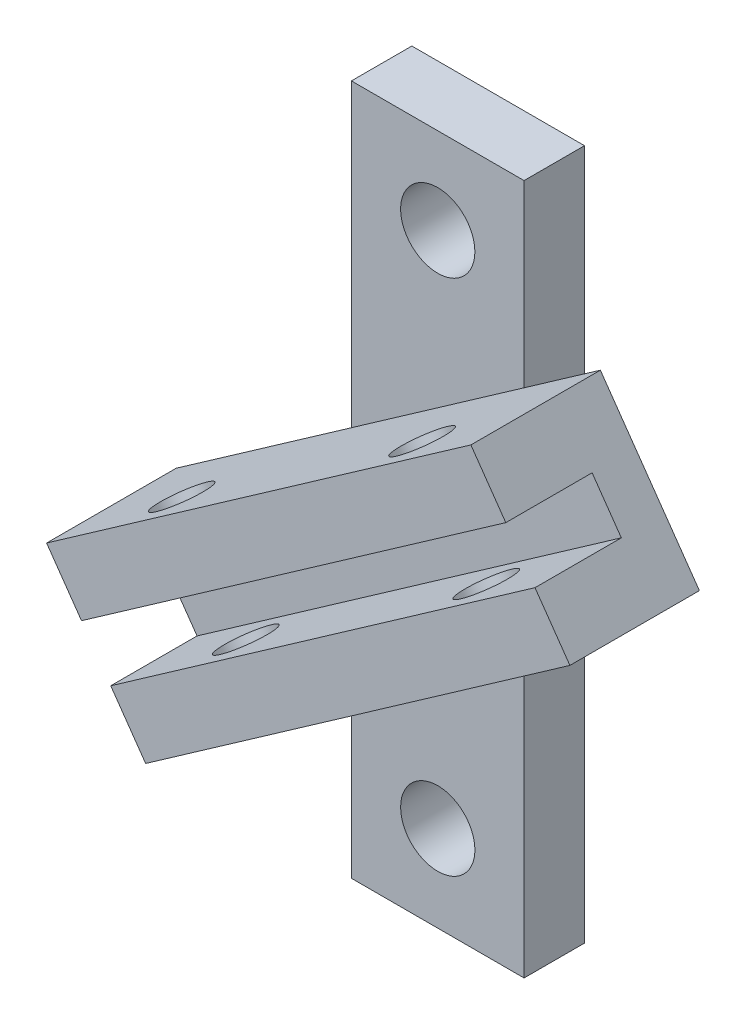
from build123d import *

# Parameters (mm, degrees)
SKIZZE1_W                       = 20
SKIZZE1_H                       = 80
SKIZZE1_R                       = 4.3
AUFSATZ_LINEAR_AUSTRAGEN1_DEPTH = 7
AUFSATZ_LINEAR_AUSTRAGEN2_DEPTH = 15
SCHNITT_LINEAR_AUSTRAGEN1_DEPTH = 10
F_6_0_6_DURCHMESSER_BOHRUNG1_D  = 6


with BuildPart() as part:
    # Skizze1 → Aufsatz-Linear austragen1 (new body)
    with BuildSketch(Plane.XY):
        with Locations((10, 40)):
            Rectangle(SKIZZE1_W, SKIZZE1_H)
        with Locations((10, 70)):
            Circle(SKIZZE1_R, mode=Mode.SUBTRACT)
        with Locations(Location((10, 10, 0), (0, 0, 180))):  # turned: the seam where the file's is
            Circle(SKIZZE1_R, mode=Mode.SUBTRACT)
    extrude(amount=AUFSATZ_LINEAR_AUSTRAGEN1_DEPTH)

    # Skizze2 → Aufsatz-Linear austragen2 (add)
    with BuildSketch(Plane.XY.offset(7)):
        Polygon((36.266611816, 54.79079456), (20, 43.400790345), (20, 34.794329494), (40.310325692, 49.015772648), align=None)
        Polygon((32.882510841, 59.623791621), (20, 50.603360419), (20, 43.400790345), (36.266611816, 54.79079456), align=None)
        Polygon((28.838796965, 65.398813533), (20, 59.20982127), (20, 50.603360419), (32.882510841, 59.623791621), align=None)
        Polygon((20, 59.20982127), (0, 45.205670506), (0, 36.599209655), (20, 50.603360419), align=None)
        Polygon((20, 50.603360419), (0, 36.599209655), (0, 29.396639581), (20, 43.400790345), align=None)
        Polygon((20, 43.400790345), (0, 29.396639581), (0, 20.79017873), (20, 34.794329494), align=None)
        Polygon((0, 29.396639581), (-12.882510841, 20.376208379), (-8.838796965, 14.601186467), (0, 20.79017873), align=None)
        Polygon((0, 36.599209655), (-16.266611816, 25.20920544), (-12.882510841, 20.376208379), (0, 29.396639581), align=None)
        Polygon((0, 45.205670506), (-20.310325692, 30.984227352), (-16.266611816, 25.20920544), (0, 36.599209655), align=None)
    extrude(amount=AUFSATZ_LINEAR_AUSTRAGEN2_DEPTH)

    # Skizze3 → Schnitt-Linear austragen1 (cut)
    with BuildSketch(Plane.XY.offset(22)):
        Polygon((-12.882510841, 20.376208379), (36.266611816, 54.79079456), (32.882510841, 59.623791621), (-16.266611816, 25.20920544), align=None)
    extrude(amount=-SCHNITT_LINEAR_AUSTRAGEN1_DEPTH, mode=Mode.SUBTRACT)

    # Ø6.0 (6) Durchmesser Bohrung1 (through all)
    with Locations(Plane(origin=(-21.239717496, 30.333460205, 0), x_dir=(0.819152044, 0.573576436, 0), z_dir=(-0.573576436, 0.819152044, 0))):
        with Locations((48.134577897, -17), (14.134577897, -17)):
            Hole(F_6_0_6_DURCHMESSER_BOHRUNG1_D / 2)


solid = part.part
